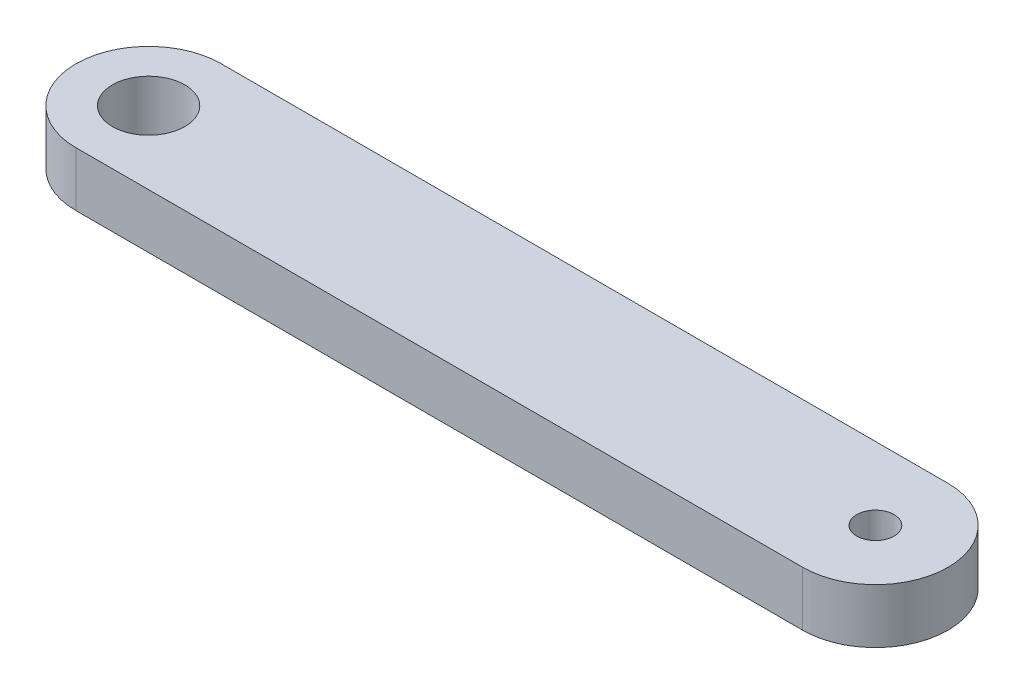
from build123d import *

# Parameters (mm, degrees)
BOSS_EXTRUDE2_DEPTH   = 4.7625
F_4_CLEARANCE_HOLE1_D = 3.2639
SKETCH5_R             = 3.1623
CUT_EXTRUDE1_DEPTH    = 5.7625


with BuildPart() as part:
    # Sketch1 → Boss-Extrude2 (new body)
    with BuildSketch(Plane(origin=(0, 0, 0), x_dir=(1, 0, 0), z_dir=(0, 1, 0))):
        with BuildLine():
            Line((-63.5, 6.35), (0, 6.35))
            ThreePointArc((0, 6.35), (6.35, 0), (0, -6.35))
            Line((0, -6.35), (-63.5, -6.35))
            ThreePointArc((-63.5, -6.35), (-69.85, 0), (-63.5, 6.35))
        make_face()
    extrude(amount=BOSS_EXTRUDE2_DEPTH)

    # #4 Clearance Hole1 (through all)
    with Locations(Plane(origin=(0, 4.7625, 0), x_dir=(1, 0, 0), z_dir=(0, 1, 0))):
        with Locations((0, 0)):
            Hole(F_4_CLEARANCE_HOLE1_D / 2)

    # Sketch5 → Cut-Extrude1 (cut, through all)
    with BuildSketch(Plane(origin=(0, 4.7625, 0), x_dir=(1, 0, 0), z_dir=(0, 1, 0))):
        with Locations((-63.5, 0)):
            Circle(SKETCH5_R)
    extrude(amount=-CUT_EXTRUDE1_DEPTH, mode=Mode.SUBTRACT)


solid = part.part
